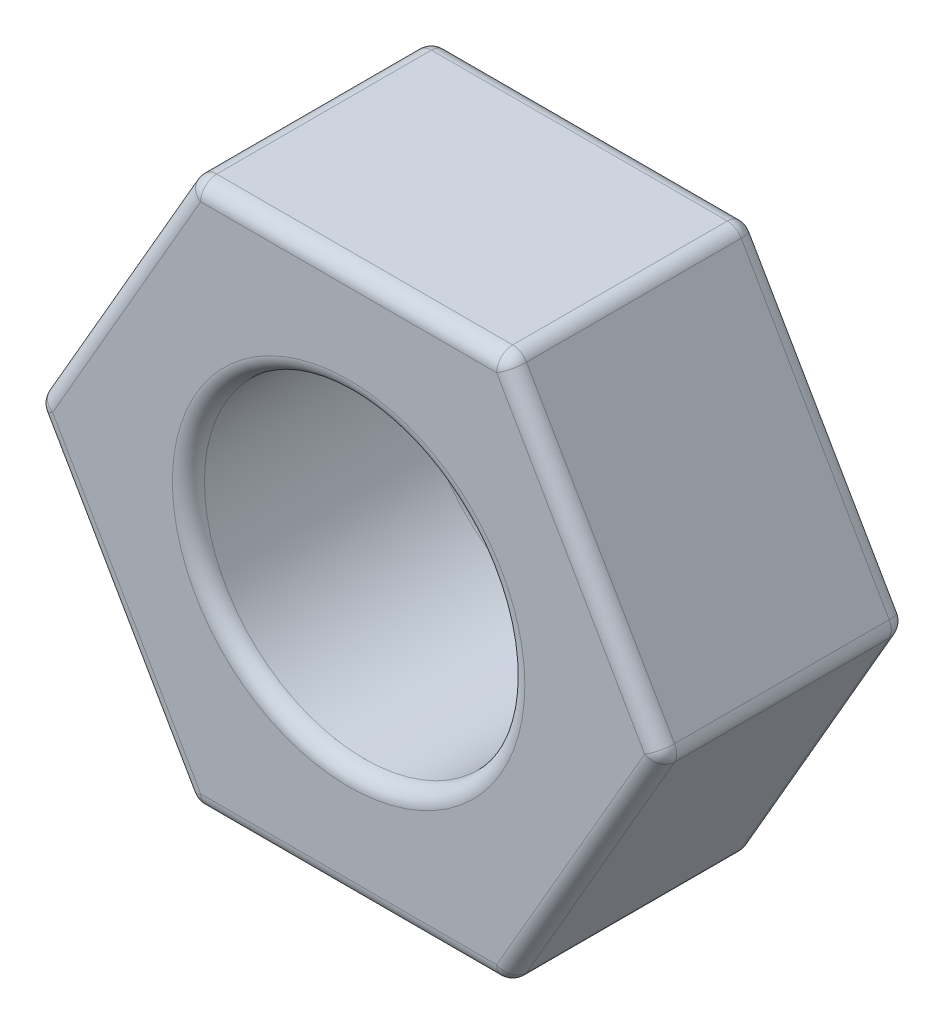
from build123d import *

# Parameters (mm, degrees)
SKIZZE1_R                       = 5
AUFSATZ_LINEAR_AUSTRAGEN1_DEPTH = 3.85
VERRUNDUNG1_R                   = 0.5


with BuildPart() as part:
    # Skizze1 → Aufsatz-Linear austragen1 (new, symmetric)
    with BuildSketch(Plane.XY):
        Polygon((-9.814954576, 0), (-4.907477288, -8.5), (4.907477288, -8.5), (9.814954576, 0), (4.907477288, 8.5), (-4.907477288, 8.5), align=None)
        Circle(SKIZZE1_R, mode=Mode.SUBTRACT)
    extrude(amount=AUFSATZ_LINEAR_AUSTRAGEN1_DEPTH, both=True)

    # Verrundung1
    verrundung1_edges = [part.edges().sort_by_distance(p)[0] for p in [
        (-4.907477288, 8.5, 0),
        (4.907477288, 8.5, 0),
        (9.814954576, 0, 0),
        (4.907477288, -8.5, 0),
        (-4.907477288, -8.5, 0),
        (-9.814954576, 0, 0),
        (0, 8.5, 3.85),
        (7.361215932, 4.25, 3.85),
        (7.361215932, -4.25, 3.85),
        (0, -8.5, 3.85),
        (-7.361215932, -4.25, 3.85),
        (-7.361215932, 4.25, 3.85),
        (0, 8.5, -3.85),
        (7.361215932, 4.25, -3.85),
        (7.361215932, -4.25, -3.85),
        (0, -8.5, -3.85),
        (-7.361215932, -4.25, -3.85),
        (-7.361215932, 4.25, -3.85),
        (-5, 0, 3.85),
        (-5, 0, -3.85),
    ]]
    fillet(verrundung1_edges, radius=VERRUNDUNG1_R)


solid = part.part
